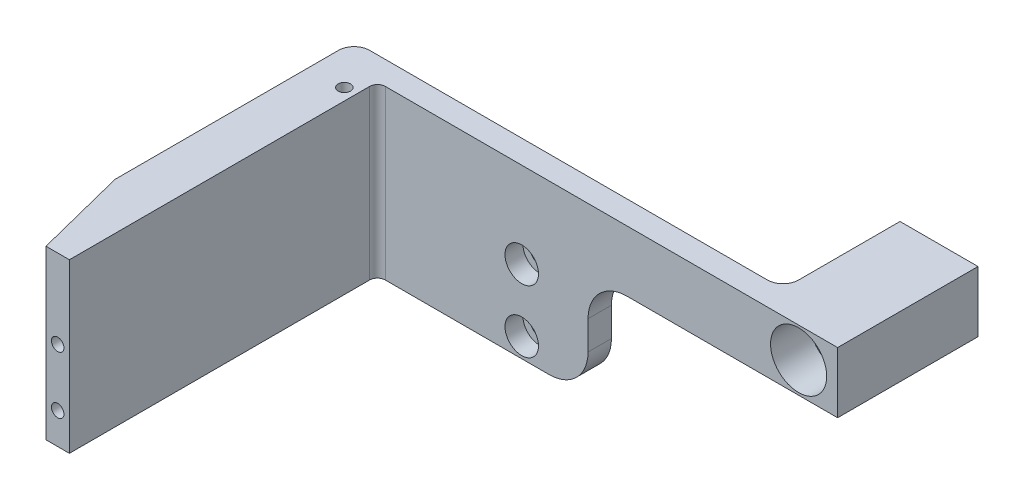
from build123d import *

# Parameters (mm, degrees)
SKETCH_1_W                = 40
SKETCH_1_H                = 10
EXTRUDE_1_DEPTH           = 3
SKETCH_2_W                = 3
SKETCH_2_H                = 10
EXTRUDE_2_DEPTH           = 39.5
EXTRUDE_3_DEPTH           = 10
FILLET_1_R                = 1
SKETCH_4_W                = 40
SKETCH_4_H                = 3
EXTRUDE_4_DEPTH           = 10
HOLE_WIZARD_1_D           = 2.4
HOLE_WIZARD_1_DEPTH       = 3.2
HOLE_WIZARD_1_CBORE_D     = 4.3
HOLE_WIZARD_1_CBORE_DEPTH = 2.3
HOLE_WIZARD_1_TIP         = 0.721032743
HOLE_WIZARD_M2_1_D        = 1.6
HOLE_WIZARD_M2_1_DEPTH    = 5.2
HOLE_WIZARD_M2_1_TIP      = 0.480688495
SKETCH_12_W               = 40
SKETCH_12_H               = 8.5
CUT_EXTRUDE_1_DEPTH       = 43.5
SKETCH_13_W               = 3
SKETCH_13_H               = 21.5
EXTRUDE_5_DEPTH           = 5
SKETCH_14_W               = 3
SKETCH_14_H               = 7.8
EXTRUDE_6_DEPTH           = 27
EXTRUDE_8_DEPTH           = 10
SKETCH_18_W               = 10.684104654
SKETCH_18_H               = 46.640580652
CUT_EXTRUDE_2_DEPTH       = 30
SKETCH_22_W               = 10
SKETCH_22_H               = 7.8
EXTRUDE_9_DEPTH           = 15
SKETCH_23_R               = 3.6
CUT_EXTRUDE_3_DEPTH       = 5
HOLE_WIZARD_M4_1_D        = 3.3
FILLET_2_R                = 2
SKETCH_26_W               = 5
SKETCH_26_H               = 13.7
CUT_EXTRUDE_4_DEPTH       = 8
EXTRUDE_10_DEPTH          = 10
EXTRUDE_11_DEPTH          = 1.5
HOLE_WIZARD_M2_2_D        = 1.6
HOLE_WIZARD_M2_2_DEPTH    = 5.2
HOLE_WIZARD_M2_2_TIP      = 0.480688495
HOLE_WIZARD_M2_3_D        = 1.6
HOLE_WIZARD_M2_3_DEPTH    = 5.2
HOLE_WIZARD_M2_3_TIP      = 0.480688495
HOLE_WIZARD_M2_4_D        = 1.6
HOLE_WIZARD_M2_4_DEPTH    = 5.2
HOLE_WIZARD_M2_4_TIP      = 0.480688495
FILLET_3_R                = 2
FILLET_4_R                = 5


with BuildPart() as part:
    # 草图1 → 凸台-拉伸1 (new body)
    with BuildSketch(Plane.XY):
        Rectangle(SKETCH_1_W, SKETCH_1_H)
    extrude(amount=EXTRUDE_1_DEPTH)

    # 草图2 → 凸台-拉伸2 (add)
    with BuildSketch(Plane.XY.offset(3)):
        with Locations((-8.5, 0)):
            Rectangle(SKETCH_2_W, SKETCH_2_H)
    extrude(amount=EXTRUDE_2_DEPTH)

    # 草图3 → 凸台-拉伸3 (add)
    with BuildSketch(Plane(origin=(0, 5, 0), x_dir=(1, 0, 0), z_dir=(0, 1, 0))):
        Polygon((-20, -3), (-10, -42.5), (-10, -30.276150361), (-16.905354522, -3), align=None)
    extrude(amount=-EXTRUDE_3_DEPTH)

    # 圆角1
    fillet_1_edges = [part.edges().sort_by_distance(p)[0] for p in [
        (-7, 0, 3),
    ]]
    fillet(fillet_1_edges, radius=FILLET_1_R)

    # 草图4 → 凸台-拉伸4 (add)
    with BuildSketch(Plane(origin=(0, 5, 0), x_dir=(1, 0, 0), z_dir=(0, 1, 0))):
        with Locations((0, -1.5)):
            Rectangle(SKETCH_4_W, SKETCH_4_H)
    extrude_4 = extrude(amount=EXTRUDE_4_DEPTH)

    # 镜向1: 凸台-拉伸4 across plane
    add(extrude_4.mirror(Plane.ZX))

    # 打孔尺寸(%根据)内六角圆柱头螺钉的类型1
    with Locations(Plane.XY.offset(3)):
        with Locations((11.5, 4), (11.5, -4)):
            CounterBoreHole(HOLE_WIZARD_1_D / 2, HOLE_WIZARD_1_CBORE_D / 2, HOLE_WIZARD_1_CBORE_DEPTH, depth=HOLE_WIZARD_1_DEPTH)
            with Locations((0, 0, -(HOLE_WIZARD_1_DEPTH + HOLE_WIZARD_1_TIP / 2))):  # 118° drill point
                Cone(0, HOLE_WIZARD_1_D / 2, HOLE_WIZARD_1_TIP, mode=Mode.SUBTRACT)

    # M2 螺纹孔1
    with Locations(Plane.XY.offset(42.5)):
        with Locations((-8.5, -2.5)):
            Hole(HOLE_WIZARD_M2_1_D / 2, depth=HOLE_WIZARD_M2_1_DEPTH)
            with Locations((0, 0, -(HOLE_WIZARD_M2_1_DEPTH + HOLE_WIZARD_M2_1_TIP / 2))):  # 118° drill point
                Cone(0, HOLE_WIZARD_M2_1_D / 2, HOLE_WIZARD_M2_1_TIP, mode=Mode.SUBTRACT)

    # 草图12 → 切除-拉伸1 (cut, through all)
    with BuildSketch(Plane(origin=(0, 0, 0), x_dir=(-1, 0, 0), z_dir=(0, 0, -1))):
        with Locations((0, -10.75)):
            Rectangle(SKETCH_12_W, SKETCH_12_H)
    extrude(amount=-CUT_EXTRUDE_1_DEPTH, mode=Mode.SUBTRACT)

    # 草图13 → 凸台-拉伸5 (add)
    with BuildSketch(Plane(origin=(20, 0, 0), x_dir=(0, 0, -1), z_dir=(1, 0, 0))):
        with Locations((-1.5, 4.25)):
            Rectangle(SKETCH_13_W, SKETCH_13_H)
    extrude(amount=EXTRUDE_5_DEPTH)

    # 草图14 → 凸台-拉伸6 (add)
    with BuildSketch(Plane(origin=(25, 0, 0), x_dir=(0, 0, -1), z_dir=(1, 0, 0))):
        with Locations((-1.5, 11.1)):
            Rectangle(SKETCH_14_W, SKETCH_14_H)
    extrude(amount=EXTRUDE_6_DEPTH)

    # 草图17 → 凸台-拉伸8 (add)
    with BuildSketch(Plane(origin=(0, 5, 0), x_dir=(1, 0, 0), z_dir=(0, 1, 0))):
        Polygon((-16.905354522, -3), (-10, -30.276150361), (-10, -3), align=None)
    extrude(amount=-EXTRUDE_8_DEPTH)

    # 草图18 → 切除-拉伸2 (cut, symmetric)
    with BuildSketch(Plane(origin=(0, 0, 0), x_dir=(1, 0, 0), z_dir=(0, 1, 0))):
        with Locations((-18.342052327, -18.918804504)):
            Rectangle(SKETCH_18_W, SKETCH_18_H)
    extrude(amount=CUT_EXTRUDE_2_DEPTH, both=True, mode=Mode.SUBTRACT)

    # 草图22 → 凸台-拉伸9 (add)
    with BuildSketch(Plane(origin=(0, 0, 0), x_dir=(-1, 0, 0), z_dir=(0, 0, -1))):
        with Locations((-47, 11.1)):
            Rectangle(SKETCH_22_W, SKETCH_22_H)
    extrude(amount=EXTRUDE_9_DEPTH)

    # 草图23 → 切除-拉伸3 (cut)
    with BuildSketch(Plane.XY.offset(3)):
        with Locations((47, 11.1)):
            Circle(SKETCH_23_R)
    extrude(amount=-CUT_EXTRUDE_3_DEPTH, mode=Mode.SUBTRACT)

    # M4 螺纹孔1 (through all)
    with Locations(Plane.XY.offset(-2)):
        with Locations((47, 11.1)):
            Hole(HOLE_WIZARD_M4_1_D / 2)

    # 圆角2
    fillet_2_edges = [part.edges().sort_by_distance(p)[0] for p in [
        (42, 11.1, 0),
    ]]
    fillet(fillet_2_edges, radius=FILLET_2_R)

    # 草图26 → 切除-拉伸4 (cut)
    with BuildSketch(Plane(origin=(0, 0, 0), x_dir=(-1, 0, 0), z_dir=(0, 0, -1))):
        with Locations((-22.5, 0.35)):
            Rectangle(SKETCH_26_W, SKETCH_26_H)
    extrude(amount=-CUT_EXTRUDE_4_DEPTH, mode=Mode.SUBTRACT)

    # 草图27 → 凸台-拉伸10 (add)
    with BuildSketch(Plane(origin=(0, 5, 0), x_dir=(1, 0, 0), z_dir=(0, 1, 0))):
        with BuildLine():
            Line((-6, -3), (-13, -3))
            Line((-13, -3), (-13, -30.65))
            Line((-13, -30.65), (-10, -42.5))
            Line((-10, -42.5), (-7, -42.5))
            Line((-7, -42.5), (-7, -4))
            ThreePointArc((-7, -4), (-6.707106781, -3.292893219), (-6, -3))
        make_face()
    extrude(amount=EXTRUDE_10_DEPTH)

    # 草图28 → 凸台-拉伸11 (add)
    with BuildSketch(Plane.XZ.offset(5)):
        with BuildLine():
            Line((-10, 42.5), (-13, 30.65))
            Line((-13, 30.65), (-13, 3))
            Line((-13, 3), (-6, 3))
            ThreePointArc((-6, 3), (-6.707106781, 3.292893219), (-7, 4))
            Line((-7, 4), (-7, 42.5))
            Line((-7, 42.5), (-10, 42.5))
        make_face()
    extrude(amount=EXTRUDE_11_DEPTH)

    # M2 螺纹孔2
    with Locations(Plane.XY.offset(42.5)):
        with Locations((-8.5, 4.854272417)):
            Hole(HOLE_WIZARD_M2_2_D / 2, depth=HOLE_WIZARD_M2_2_DEPTH)
            with Locations((0, 0, -(HOLE_WIZARD_M2_2_DEPTH + HOLE_WIZARD_M2_2_TIP / 2))):  # 118° drill point
                Cone(0, HOLE_WIZARD_M2_2_D / 2, HOLE_WIZARD_M2_2_TIP, mode=Mode.SUBTRACT)

    # M2 螺纹孔3
    with Locations(Plane(origin=(0, -6.5, 0), x_dir=(-1, 0, 0), z_dir=(0, -1, 0))):
        with Locations((8.5, -5.75)):
            Hole(HOLE_WIZARD_M2_3_D / 2, depth=HOLE_WIZARD_M2_3_DEPTH)
            with Locations((0, 0, -(HOLE_WIZARD_M2_3_DEPTH + HOLE_WIZARD_M2_3_TIP / 2))):  # 118° drill point
                Cone(0, HOLE_WIZARD_M2_3_D / 2, HOLE_WIZARD_M2_3_TIP, mode=Mode.SUBTRACT)

    # M2 螺纹孔4
    with Locations(Plane(origin=(0, 15, 0), x_dir=(1, 0, 0), z_dir=(0, 1, 0))):
        with Locations((-8.5, -5.75)):
            Hole(HOLE_WIZARD_M2_4_D / 2, depth=HOLE_WIZARD_M2_4_DEPTH)
            with Locations((0, 0, -(HOLE_WIZARD_M2_4_DEPTH + HOLE_WIZARD_M2_4_TIP / 2))):  # 118° drill point
                Cone(0, HOLE_WIZARD_M2_4_D / 2, HOLE_WIZARD_M2_4_TIP, mode=Mode.SUBTRACT)

    # 圆角3
    fillet_3_edges = [part.edges().sort_by_distance(p)[0] for p in [
        (-13, 4.25, 0),
    ]]
    fillet(fillet_3_edges, radius=FILLET_3_R)

    # 圆角4
    fillet_4_edges = [part.edges().sort_by_distance(p)[0] for p in [
        (20, 7.2, 1.5),
        (20, -6.5, 1.5),
    ]]
    fillet(fillet_4_edges, radius=FILLET_4_R)


solid = part.part
